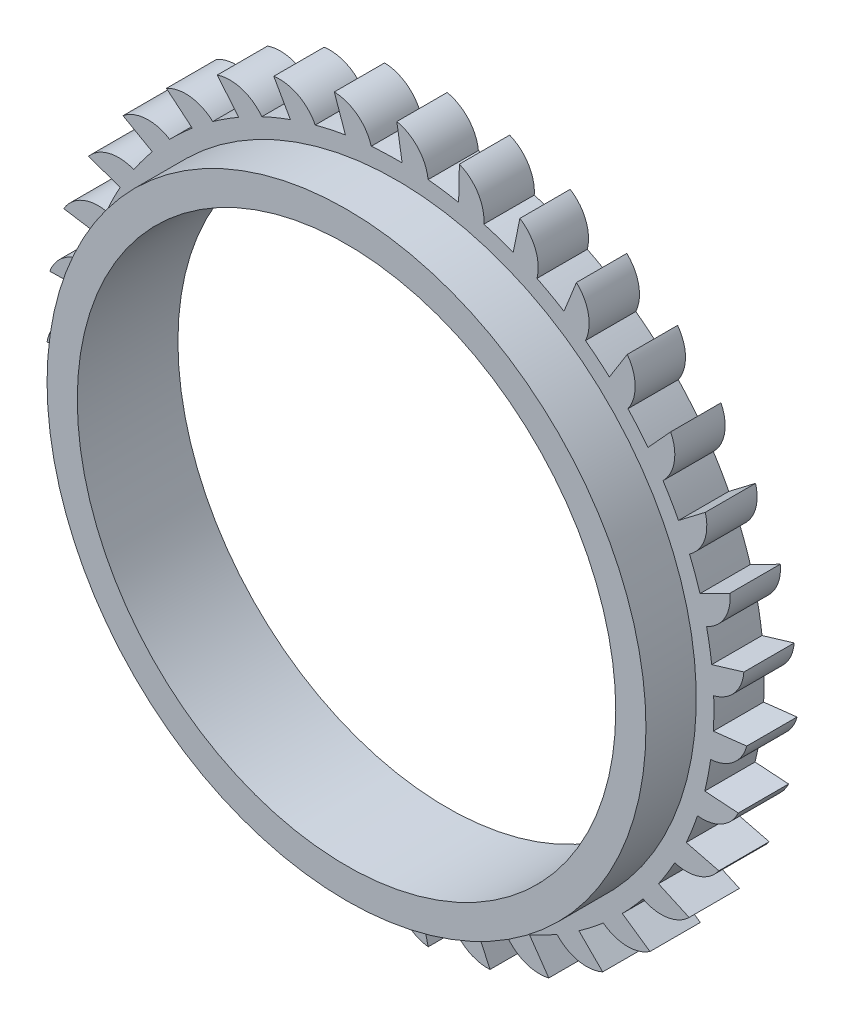
from build123d import *

# Parameters (mm, degrees)
BOSS_EXTRUDE1_DEPTH = 10
SKETCH2_R           = 59.5
SKETCH2_R_2         = 53.5
BOSS_EXTRUDE2_DEPTH = 10
SKETCH3_R           = 53.5
CUT_EXTRUDE4_DEPTH  = 10


with BuildPart() as part:
    # Sketch1 → Boss-Extrude1 (new body)
    with BuildSketch(Plane.XY):
        with BuildLine():
            Line((0, 69.588014501), (1.048611539, 62.991272521))
            ThreePointArc((1.048611539, 62.991272521), (-2.021331039, 62.967564832), (-5.0864736, 62.794329253))
            ThreePointArc((-5.0864736, 62.794329253), (-7.836974129, 66.820360054), (-12.425419784, 68.469706479))
            Line((-12.425419784, 68.469706479), (-10.2157661, 62.166213677))
            ThreePointArc((-10.2157661, 62.166213677), (-13.232140267, 61.594727566), (-16.217092319, 60.876973617))
            ThreePointArc((-16.217092319, 60.876973617), (-19.642266731, 64.347183613), (-24.451476353, 65.150725754))
            Line((-24.451476353, 65.150725754), (-21.151800612, 59.343081576))
            ThreePointArc((-21.151800612, 59.343081576), (-24.017657619, 58.242185077), (-26.826480348, 57.002981958))
            ThreePointArc((-26.826480348, 57.002981958), (-30.816240719, 59.805835745), (-35.691642354, 59.737747098))
            Line((-35.691642354, 59.737747098), (-31.407998848, 54.612614004))
            ThreePointArc((-31.407998848, 54.612614004), (-34.031227694, 53.017690837), (-36.573643225, 51.296867558))
            ThreePointArc((-36.573643225, 51.296867558), (-40.999755374, 53.342279108), (-45.784649601, 52.404748097))
            Line((-45.784649601, 52.404748097), (-40.654718159, 48.126852083))
            ThreePointArc((-40.654718159, 48.126852083), (-42.951006109, 46.08916439), (-45.145299116, 43.942029627))
            ThreePointArc((-45.145299116, 43.942029627), (-49.865504157, 45.164257731), (-54.406100539, 43.387417373))
            Line((-54.406100539, 43.387417373), (-48.594761377, 40.094253538))
            ThreePointArc((-48.594761377, 40.094253538), (-50.490303849, 37.679294278), (-52.265947947, 35.174858708))
            ThreePointArc((-52.265947947, 35.174858708), (-57.128534607, 35.534619949), (-61.27889464, 32.975579356))
            Line((-61.27889464, 32.975579356), (-54.97292898, 30.772992693))
            ThreePointArc((-54.97292898, 30.772992693), (-56.406801678, 28.058380645), (-57.706726208, 25.277138889))
            ThreePointArc((-57.706726208, 25.277138889), (-62.555406949, 24.762870243), (-66.182134647, 21.503879086))
            Line((-66.182134647, 21.503879086), (-59.584221415, 20.462662544))
            ThreePointArc((-59.584221415, 20.462662544), (-60.510338491, 17.535647571), (-61.292762806, 14.566991027))
            ThreePointArc((-61.292762806, 14.566991027), (-65.97169704, 13.195221514), (-68.958226392, 9.341026448))
            Line((-68.958226392, 9.341026448), (-62.280427947, 9.494645584))
            ThreePointArc((-62.280427947, 9.494645584), (-62.669023236, 6.449304357), (-62.908799576, 3.388648088))
            ThreePointArc((-62.908799576, 3.388648088), (-67.267602508, 1.203467507), (-69.517944001, -3.122054465))
            Line((-69.517944001, -3.122054465), (-62.97489028, -1.778537098))
            ThreePointArc((-62.97489028, -1.778537098), (-62.81347401, -4.844324807), (-62.502895767, -7.898608789))
            ThreePointArc((-62.502895767, -7.898608789), (-66.401471883, -10.826966935), (-67.84329769, -15.484789979))
            Line((-67.84329769, -15.484789979), (-61.645287824, -12.994556134))
            ThreePointArc((-61.645287824, -12.994556134), (-60.939048046, -15.982253385), (-60.088097459, -18.93199788))
            ThreePointArc((-60.088097459, -18.93199788), (-63.401143316, -22.509413752), (-63.98811197, -27.349831602))
            Line((-63.98811197, -27.349831602), (-58.334355095, -23.792919443))
            ThreePointArc((-58.334355095, -23.792919443), (-57.105990937, -26.606499189), (-55.742018259, -29.356896982))
            ThreePointArc((-55.742018259, -29.356896982), (-58.363049836, -33.468389489), (-58.076295682, -38.335827134))
            Line((-58.076295682, -38.335827134), (-53.148508196, -33.826558745))
            ThreePointArc((-53.148508196, -33.826558745), (-51.437500293, -36.375590217), (-49.604344727, -38.83824126))
            ThreePointArc((-49.604344727, -38.83824126), (-51.449119914, -43.351663651), (-50.297859465, -48.089677639))
            Line((-50.297859465, -48.089677639), (-46.254424513, -42.772984617))
            ThreePointArc((-46.254424513, -42.772984617), (-44.115766066, -44.975539846), (-41.872346741, -47.071292508))
            ThreePointArc((-41.872346741, -47.071292508), (-42.881572944, -51.841579673), (-40.90280866, -56.297886336))
            Line((-40.90280866, -56.297886336), (-37.873685567, -50.344651569))
            ThreePointArc((-37.873685567, -50.344651569), (-35.376114819, -52.129938618), (-32.794537078, -53.791433684))
            ThreePointArc((-32.794537078, -53.791433684), (-32.935776938, -58.665264669), (-30.193107929, -62.696634645))
            Line((-30.193107929, -62.696634645), (-28.275655205, -56.298199996))
            ThreePointArc((-28.275655205, -56.298199996), (-25.499446135, -57.60883827), (-22.66268401, -58.782673922))
            ThreePointArc((-22.66268401, -58.782673922), (-21.931397961, -63.603399789), (-18.512975867, -67.080261528))
            Line((-18.512975867, -67.080261528), (-17.768822019, -60.442277952))
            ThreePointArc((-17.768822019, -60.442277952), (-14.80320427, -61.23614246), (-11.802433631, -61.884590654))
            ThreePointArc((-11.802433631, -61.884590654), (-10.222125808, -66.497269306), (-6.237821528, -69.307873613))
            Line((-6.237821528, -69.307873613), (-6.690884273, -62.643691363))
            ThreePointArc((-6.690884273, -62.643691363), (-3.631175241, -62.895266645), (-0.562843324, -62.997485723))
            ThreePointArc((-0.562843324, -62.997485723), (1.815693879, -67.253861874), (6.237821528, -69.307873613))
            Line((6.237821528, -69.307873613), (4.602103998, -62.831684991))
            ThreePointArc((4.602103998, -62.831684991), (7.657562749, -62.53288521), (10.69483723, -62.085589766))
            ThreePointArc((10.69483723, -62.085589766), (13.795155671, -65.848859984), (18.512975867, -67.080261528))
            Line((18.512975867, -67.080261528), (15.74717686, -61.000216565))
            ThreePointArc((15.74717686, -61.000216565), (18.700180371, -60.160645393), (21.608776916, -59.17821187))
            ThreePointArc((21.608776916, -59.17821187), (25.331229809, -62.327421554), (30.193107929, -62.696634645))
            Line((30.193107929, -62.696634645), (26.386122502, -57.208150987))
            ThreePointArc((26.386122502, -57.208150987), (29.14175881, -55.854792932), (31.828192733, -54.368797553))
            ThreePointArc((31.828192733, -54.368797553), (36.053137378, -56.802728512), (40.90280866, -56.297886336))
            Line((40.90280866, -56.297886336), (36.176996455, -51.577368365))
            ThreePointArc((36.176996455, -51.577368365), (38.646697142, -49.753721469), (41.024624246, -47.811925348))
            ThreePointArc((41.024624246, -47.811925348), (45.616267447, -49.452349038), (50.297859465, -48.089677639))
            Line((50.297859465, -48.089677639), (44.805111976, -44.288846686))
            ThreePointArc((44.805111976, -44.288846686), (46.90949883, -42.05352446), (48.902490582, -39.718338522))
            ThreePointArc((48.902490582, -39.718338522), (53.713253147, -40.512530377), (58.076295682, -38.335827134))
            Line((58.076295682, -38.335827134), (51.993154332, -35.576845034))
            ThreePointArc((51.993154332, -35.576845034), (53.664590628, -33.001692573), (55.208590632, -30.348171615))
            ThreePointArc((55.208590632, -30.348171615), (60.083850696, -30.270605655), (63.98811197, -27.349831602))
            Line((63.98811197, -27.349831602), (57.510093928, -25.72137431))
            ThreePointArc((57.510093928, -25.72137431), (58.694858328, -22.889159134), (59.740241154, -20.002589503))
            ThreePointArc((59.740241154, -20.002589503), (64.523303846, -19.055758761), (67.84329769, -15.484789979))
            Line((67.84329769, -15.484789979), (61.178611786, -15.039197451))
            ThreePointArc((61.178611786, -15.039197451), (61.838624987, -12.040949286), (62.351791171, -9.014107705))
            ThreePointArc((62.351791171, -9.014107705), (66.888924921, -7.228444101), (69.517944001, -3.122054465))
            Line((69.517944001, -3.122054465), (62.880798722, -3.873648413))
            ThreePointArc((62.880798722, -3.873648413), (62.994847358, -0.805733421), (62.959303317, 2.264094931))
            ThreePointArc((62.959303317, 2.264094931), (67.104680912, 4.8311987), (68.958226392, 9.341026448))
            Line((68.958226392, 9.341026448), (62.56194505, 7.416402873))
            ThreePointArc((62.56194505, 7.416402873), (62.126363502, 10.455379379), (61.543251651, 13.469527693))
            ThreePointArc((61.543251651, 13.469527693), (65.163637245, 16.735562799), (66.182134647, 21.503879086))
            Line((66.182134647, 21.503879086), (60.232298987, 18.468084869))
            ThreePointArc((60.232298987, 18.468084869), (59.261087206, 21.380447683), (58.149149238, 24.242038752))
            ThreePointArc((58.149149238, 24.242038752), (61.12818066, 28.10203214), (61.27889464, 32.975579356))
            Line((61.27889464, 32.975579356), (55.966737276, 28.926187421))
            ThreePointArc((55.966737276, 28.926187421), (54.491110807, 31.618330807), (52.886085324, 34.235390739))
            ThreePointArc((52.886085324, 34.235390739), (55.128014052, 38.565279046), (54.406100539, 43.387417373))
            Line((54.406100539, 43.387417373), (49.902358579, 38.454578509))
            ThreePointArc((49.902358579, 38.454578509), (47.969745271, 40.839974763), (45.923219113, 43.128389099))
            ThreePointArc((45.923219113, 43.128389099), (47.355987713, 47.789006151), (45.784649601, 52.404748097))
            Line((45.784649601, 52.404748097), (42.234077017, 46.747007803))
            ThreePointArc((42.234077017, 46.747007803), (39.906592652, 48.748988327), (37.484342854, 50.635205547))
            ThreePointArc((37.484342854, 50.635205547), (38.061900964, 55.476755278), (35.691642354, 59.737747098))
            Line((35.691642354, 59.737747098), (33.20835747, 53.536949802))
            ThreePointArc((33.20835747, 53.536949802), (30.560809311, 55.091169295), (27.840688973, 56.514564826))
            ThreePointArc((27.840688973, 56.514564826), (27.544473401, 61.381435844), (24.451476353, 65.150725754))
            Line((24.451476353, 65.150725754), (23.11529399, 58.606170185))
            ThreePointArc((23.11529399, 58.606170185), (20.232776412, 59.662674753), (17.302212441, 60.577499491))
            ThreePointArc((17.302212441, 60.577499491), (16.141743799, 65.313266557), (12.425419784, 68.469706479))
            Line((12.425419784, 68.469706479), (12.279285941, 61.791740037))
            ThreePointArc((12.279285941, 61.791740037), (9.254445432, 62.316572754), (6.207628565, 62.69342348))
            ThreePointArc((6.207628565, 62.69342348), (4.22020527, 67.145875143), (0, 69.588014501))
        make_face()
    extrude(amount=BOSS_EXTRUDE1_DEPTH)

    # Sketch2 → Boss-Extrude2 (add)
    with BuildSketch(Plane.XY.offset(10)):
        with Locations(Location((0, 0, 0), (0, 0, 180))):  # turned: the seam where the file's is
            Circle(SKETCH2_R)
        Circle(SKETCH2_R_2, mode=Mode.SUBTRACT)
    extrude(amount=BOSS_EXTRUDE2_DEPTH)

    # Sketch3 → Cut-Extrude4 (cut)
    with BuildSketch(Plane.XY.offset(10)):
        Circle(SKETCH3_R)
    extrude(amount=-CUT_EXTRUDE4_DEPTH, mode=Mode.SUBTRACT)


solid = part.part
